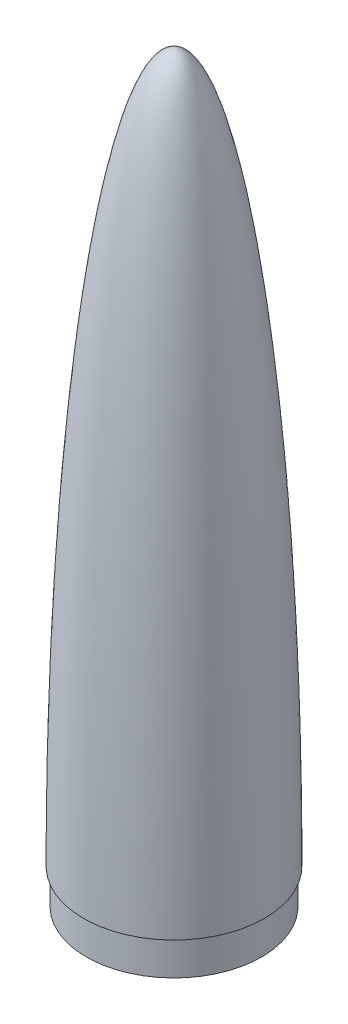
from build123d import *

# Parameters (mm, degrees)
CROQUIS4_R            = 1.6
CORTAR_EXTRUIR1_DEPTH = 10


with BuildPart() as part:
    # Croquis1 → Revolución1 (revolve)
    with BuildSketch(Plane.XY):
        with BuildLine():
            add(Edge.make_bspline(
                [(37.79, 0), (37.79, 9.960236444), (37.664694442, 29.935572546), (37.102655042, 59.565861984), (36.171920492, 88.633245112), (34.451616706, 126.246412144), (31.431973521, 170.440975848), (26.556684844, 216.90935024), (21.609420408, 248.663260812), (17.240887319, 269.142472583), (13.795202072, 281.88820718), (10.223461032, 291.880973096), (7.191615394, 297.807361864), (4.801622063, 301.042747952), (3.071446776, 302.705487017), (1.448432646, 303.619825673), (0.50343541, 303.8), (0, 303.8)],
                knots=[-1.570796327, -1.570796327, -1.570796327, -1.570796327, -1.472621556, -1.374446786, -1.276272016, -1.178097245, -0.981747704, -0.785398163, -0.589048623, -0.490873852, -0.392699082, -0.294524311, -0.196349541, -0.147262156, -0.09817477, -0.049087385, 0, 0, 0, 0], degree=3))
            Line((0, 303.8), (0, 305))
            add(Edge.make_bspline(
                [(38.99, 0), (38.99, 305), (0, 305)],
                knots=[4.71238898, 4.71238898, 4.71238898, 6.283185307, 6.283185307, 6.283185307], degree=2, weights=[1, 0.707106781, 1]))
            Line((38.99, 0), (37.79, 0))
        make_face()
    revolve(axis=Axis((0, 0, 0), (0, 1, 0)))

    # Sketch1 → Revolve1 (revolve)
    with BuildSketch(Plane.XY):
        Polygon((37.79, 0), (37.79, -15), (36.29, -15), (36.29, 0), (36.29, 1.5), (37.79, 3), (37.79, 1.5), align=None)
    revolve(axis=Axis((0, 0, 0), (0, 1, 0)))


with BuildPart() as body_2:
    # Croquis3 → Revolución2 (revolve)
    with BuildSketch(Plane.XY):
        Polygon((36.285517958, 1.5), (31.288109015, 1.5), (31.288109015, 2.998109015), (37.788109015, 2.998109015), align=None)
    revolve(axis=Axis((0, 0, 0), (0, -1, 0)))

    # Croquis4 → Cortar-Extruir1 (cut)
    with BuildSketch(Plane.XZ.offset(-1.5)):
        with Locations((-14, 30)):
            Circle(CROQUIS4_R)
        with Locations((14, 30)):
            Circle(CROQUIS4_R)
        with Locations((14, -30)):
            Circle(CROQUIS4_R)
        with Locations((-14, -30)):
            Circle(CROQUIS4_R)
    extrude(amount=-CORTAR_EXTRUIR1_DEPTH, mode=Mode.SUBTRACT)


solid = Compound([part.part, body_2.part])
